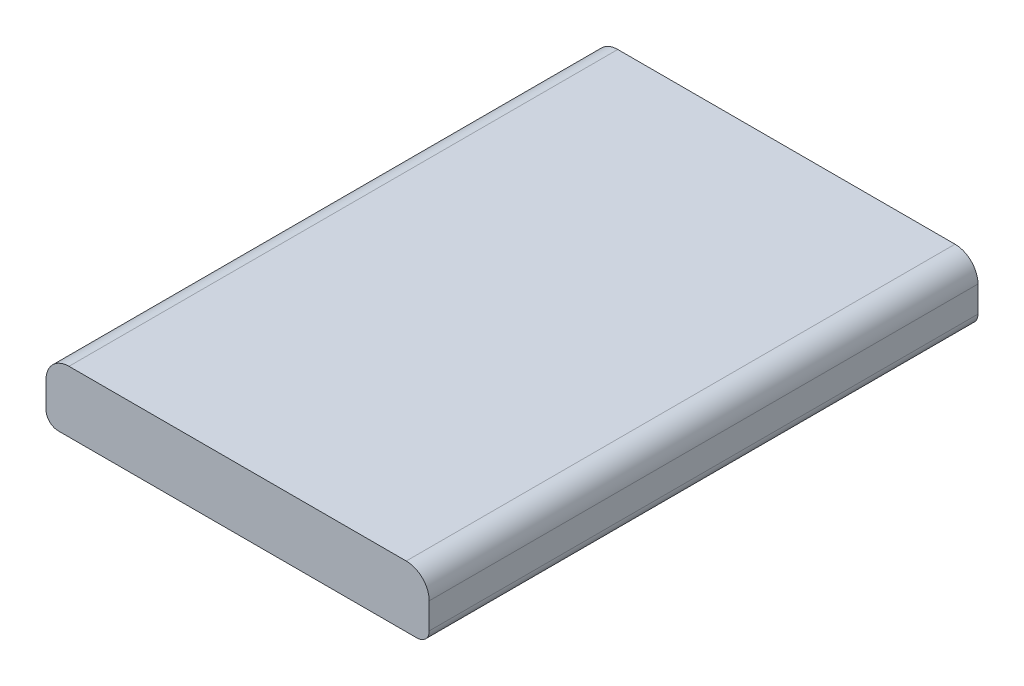
from build123d import *

# Parameters (mm, degrees)
SKETCH1_W           = 25
SKETCH1_H           = 35.8
BOSS_EXTRUDE1_DEPTH = 4
FILLET1_R           = 1.5
FILLET2_R           = 0.8


with BuildPart() as part:
    # Sketch1 → Boss-Extrude1 (new body)
    with BuildSketch(Plane(origin=(0, 0, 0), x_dir=(1, 0, 0), z_dir=(0, 1, 0))):
        Rectangle(SKETCH1_W, SKETCH1_H)
    extrude(amount=BOSS_EXTRUDE1_DEPTH)

    # Fillet1
    fillet1_edges = [part.edges().sort_by_distance(p)[0] for p in [
        (-12.5, 4, 0),
        (12.5, 4, 0),
    ]]
    fillet(fillet1_edges, radius=FILLET1_R)

    # Fillet2
    fillet2_edges = [part.edges().sort_by_distance(p)[0] for p in [
        (-12.5, 0, 0),
        (12.5, 0, 0),
    ]]
    fillet(fillet2_edges, radius=FILLET2_R)


solid = part.part
